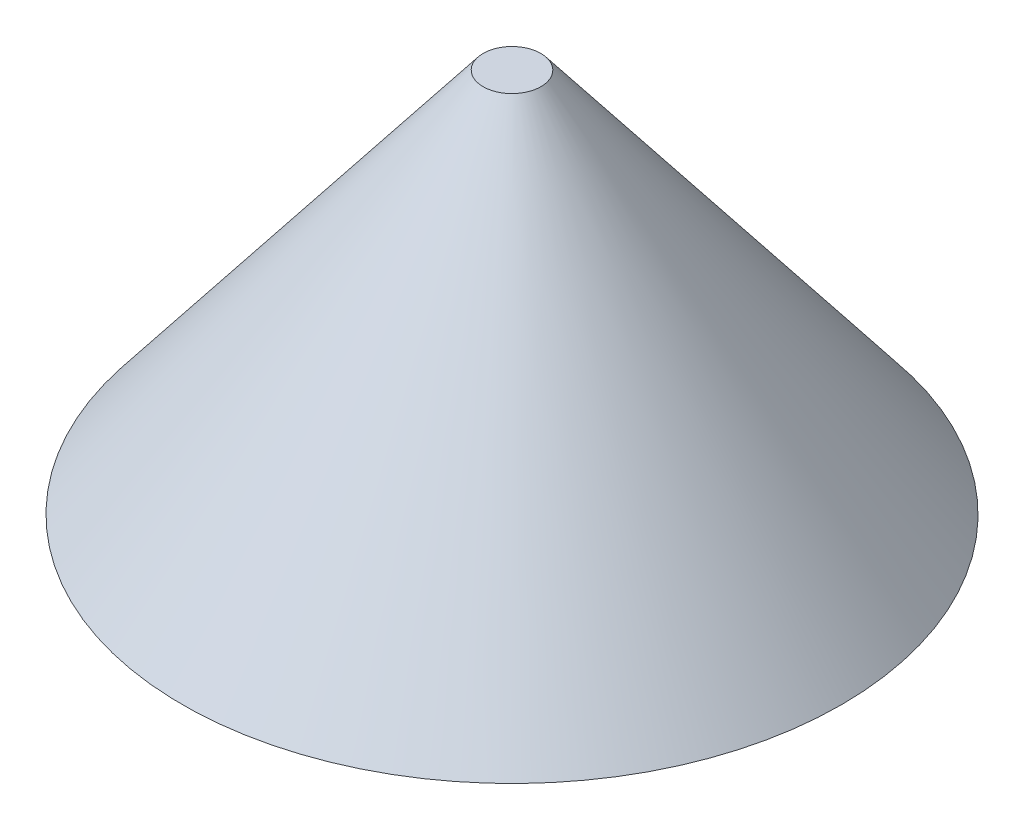
from build123d import *


with BuildPart() as part:
    # 草图1 → 旋转1 (revolve)
    with BuildSketch(Plane.XY):
        Polygon((0, 0), (0, -60), (-51.37713759, -60), (-4.5, 0), align=None)
    revolve(axis=Axis((0, 0, 0), (0, -1, 0)))


solid = part.part
